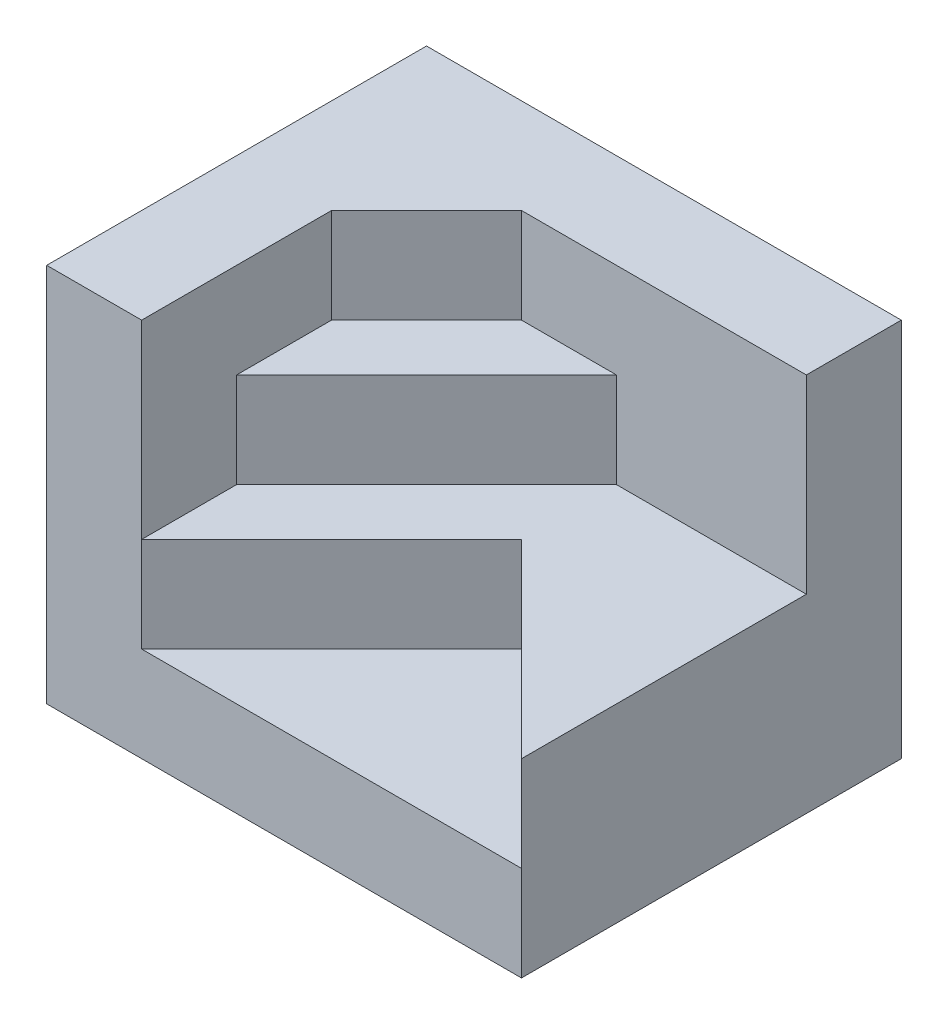
from build123d import *

# Parameters (mm, degrees)
SKETCH_1_W               = 50
SKETCH_1_H               = 40
EXTRUDE_1_DEPTH          = 40
CUT_EXTRUDE_1_DEPTH      = 30
CUT_EXTRUDE_2_DEPTH      = 1
CUT_EXTRUDE_2_DEPTH_BACK = 20
EXTRUDE_2_DEPTH          = 10


with BuildPart() as part:
    # 草圖1 → 填料-伸長1 (new body)
    with BuildSketch(Plane(origin=(0, 0, 0), x_dir=(1, 0, 0), z_dir=(0, 1, 0))):
        Rectangle(SKETCH_1_W, SKETCH_1_H)
    extrude(amount=EXTRUDE_1_DEPTH)

    # 草圖2 → 除料-伸長1 (cut)
    with BuildSketch(Plane(origin=(0, 40, 0), x_dir=(1, 0, 0), z_dir=(0, 1, 0))):
        Polygon((25, -20), (5, 0), (-15, -20), align=None)
    extrude(amount=-CUT_EXTRUDE_1_DEPTH, mode=Mode.SUBTRACT)

    # 草圖3 → 除料-伸長2 (cut, two sides)
    with BuildSketch(Plane(origin=(0, 40, 0), x_dir=(1, 0, 0), z_dir=(0, 1, 0))) as cut_extrude_2_sk:
        Polygon((151.619037897, 10), (25, 10), (-5, 10), (-15, 0), (-15, -20), (-15, -146.619037897), (158.443612564, -331.136886065), (325.062650461, -174.517848168), align=None)
    extrude(amount=CUT_EXTRUDE_2_DEPTH, mode=Mode.SUBTRACT)
    extrude(cut_extrude_2_sk.sketch, amount=-CUT_EXTRUDE_2_DEPTH_BACK, mode=Mode.SUBTRACT)

    # 草圖4 → 填料-伸長2 (add)
    with BuildSketch(Plane(origin=(0, 20, 0), x_dir=(1, 0, 0), z_dir=(0, 1, 0))):
        Polygon((-15, -10), (5, 10), (-5, 10), (-15, 0), align=None)
    extrude(amount=EXTRUDE_2_DEPTH)


solid = part.part
